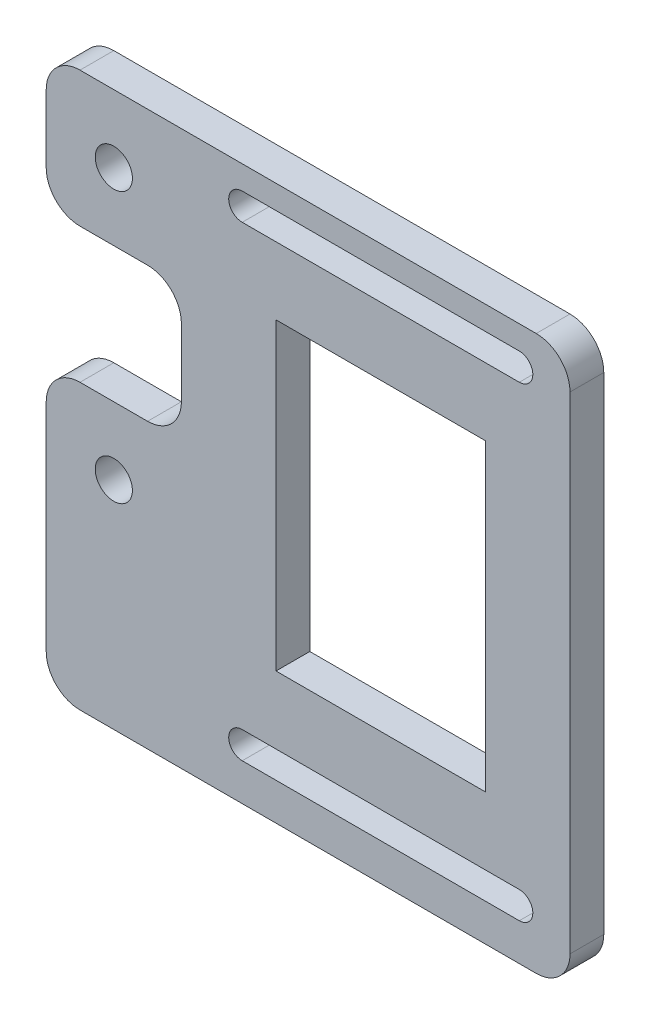
from build123d import *

# Parameters (mm, degrees)
SKETCH2_W            = 31
SKETCH2_H            = 45
BOSS_EXTRUDE1_DEPTH  = 5
M5_CLEARANCE_HOLE1_D = 5.5
FILLET1_R            = 5


with BuildPart() as part:
    # Sketch2 → Boss-Extrude1 (new body)
    with BuildSketch(Plane.XY):
        Polygon((-10, 30), (-10, 10), (10, 10), (10, -10), (-10, -10), (-10, -52), (67.5, -52), (67.5, 30), align=None)
        with BuildLine():
            Line((19, 26.5), (60, 26.5))
            ThreePointArc((60, 26.5), (62, 24.5), (60, 22.5))
            Line((60, 22.5), (19, 22.5))
            ThreePointArc((19, 22.5), (17, 24.5), (19, 26.5))
        make_face(mode=Mode.SUBTRACT)
        with BuildLine():
            Line((19, -42.5), (60, -42.5))
            ThreePointArc((60, -42.5), (62, -44.5), (60, -46.5))
            Line((60, -46.5), (19, -46.5))
            ThreePointArc((19, -46.5), (17, -44.5), (19, -42.5))
        make_face(mode=Mode.SUBTRACT)
        with Locations((39.5, -10)):
            Rectangle(SKETCH2_W, SKETCH2_H, mode=Mode.SUBTRACT)
    extrude(amount=BOSS_EXTRUDE1_DEPTH)

    # M5 Clearance Hole1 (through all)
    with Locations(Plane.XY.offset(5)):
        with Locations((0, 20), (0, -20)):
            Hole(M5_CLEARANCE_HOLE1_D / 2)

    # Fillet1
    fillet1_edges = [part.edges().sort_by_distance(p)[0] for p in [
        (67.5, 30, 2.5),
        (67.5, -52, 2.5),
        (-10, -52, 2.5),
        (-10, -10, 2.5),
        (10, -10, 2.5),
        (10, 10, 2.5),
        (-10, 10, 2.5),
        (-10, 30, 2.5),
    ]]
    fillet(fillet1_edges, radius=FILLET1_R)


solid = part.part
